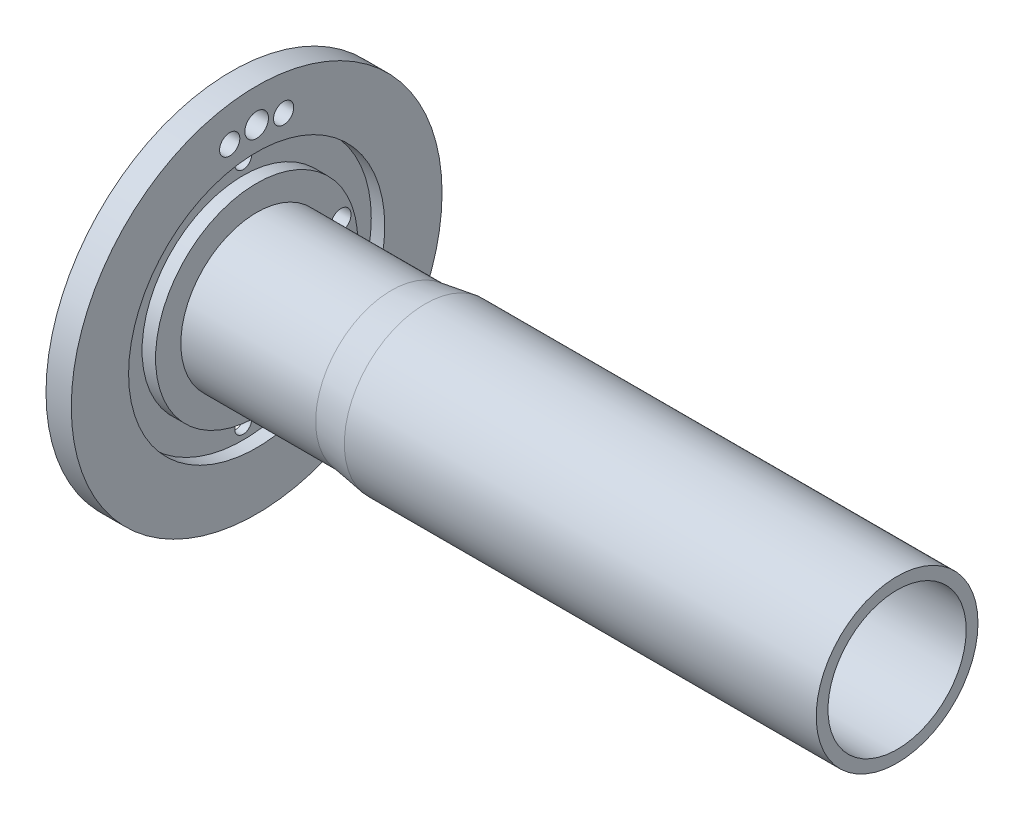
from build123d import *

# Parameters (mm, degrees)
SKETCH2_R               = 55
BOSS_EXTRUDE1_DEPTH     = 10
SKETCH3_R               = 22.5
BOSS_EXTRUDE2_DEPTH     = 40
SKETCH4_R               = 19
CUT_EXTRUDE1_DEPTH      = 93.466210045
CUT_EXTRUDE1_DEPTH_BACK = 93.466210045
SKETCH14_R              = 37.5
SKETCH14_R_2            = 30.5
CUT_EXTRUDE5_DEPTH      = 3
SKETCH15_R              = 38
SKETCH15_R_2            = 30
CUT_EXTRUDE6_DEPTH      = 4
SKETCH16_R              = 2.5
CUT_EXTRUDE7_DEPTH      = 93.466210045
SKETCH17_R              = 5
CUT_EXTRUDE8_DEPTH      = 3.7
SKETCH20_R              = 3.5
SKETCH20_R_2            = 3
CUT_EXTRUDE9_DEPTH      = 10
SKETCH21_R              = 3.5
SKETCH21_R_2            = 3
CUT_EXTRUDE10_DEPTH     = 10
SKETCH22_R              = 24
BOSS_EXTRUDE3_DEPTH     = 140
SKETCH23_R              = 20.5
CUT_EXTRUDE11_DEPTH     = 140
SKETCH25_R              = 103.972470389
CUT_EXTRUDE12_DEPTH     = 2.5


with BuildPart() as part:
    # Sketch2 → Boss-Extrude1 (new body)
    with BuildSketch(Plane(origin=(0, 0, 0), x_dir=(0, 0, -1), z_dir=(1, 0, 0))):
        Circle(SKETCH2_R)
    extrude(amount=BOSS_EXTRUDE1_DEPTH)

    # Sketch3 → Boss-Extrude2 (add)
    with BuildSketch(Plane(origin=(10, 0, 0), x_dir=(0, 0, -1), z_dir=(1, 0, 0))):
        Circle(SKETCH3_R)
    extrude(amount=BOSS_EXTRUDE2_DEPTH)

    # Sketch4 → Cut-Extrude1 (cut, two sides)
    with BuildSketch(Plane.ZY) as cut_extrude1_sk:
        Circle(SKETCH4_R)
    extrude(amount=CUT_EXTRUDE1_DEPTH, mode=Mode.SUBTRACT)
    extrude(cut_extrude1_sk.sketch, amount=-CUT_EXTRUDE1_DEPTH_BACK, mode=Mode.SUBTRACT)

    # Sketch14 → Cut-Extrude5 (cut)
    with BuildSketch(Plane.ZY):
        Circle(SKETCH14_R)
        Circle(SKETCH14_R_2, mode=Mode.SUBTRACT)
    extrude(amount=-CUT_EXTRUDE5_DEPTH, mode=Mode.SUBTRACT)

    # Sketch15 → Cut-Extrude6 (cut)
    with BuildSketch(Plane(origin=(10, 0, 0), x_dir=(0, 0, -1), z_dir=(1, 0, 0))):
        Circle(SKETCH15_R)
        Circle(SKETCH15_R_2, mode=Mode.SUBTRACT)
    extrude(amount=-CUT_EXTRUDE6_DEPTH, mode=Mode.SUBTRACT)

    # Sketch16 → Cut-Extrude7 (cut, through all)
    with BuildSketch(Plane.ZY):
        with Locations((0, 34)):
            Circle(SKETCH16_R)
        with Locations((0, -34)):
            Circle(SKETCH16_R)
    extrude(amount=-CUT_EXTRUDE7_DEPTH, mode=Mode.SUBTRACT)

    # Sketch17 → Cut-Extrude8 (cut)
    with BuildSketch(Plane.ZY):
        with Locations((0, -34)):
            Circle(SKETCH17_R)
        with Locations((0, 34)):
            Circle(SKETCH17_R)
    extrude(amount=-CUT_EXTRUDE8_DEPTH, mode=Mode.SUBTRACT)

    # Sketch20 → Cut-Extrude9 (cut)
    with BuildSketch(Plane.ZY):
        with Locations((-26, 0)):
            Circle(SKETCH20_R)
        with Locations((-25, -8)):
            Circle(SKETCH20_R_2)
        with Locations((-25, 8)):
            Circle(SKETCH20_R_2)
    extrude(amount=-CUT_EXTRUDE9_DEPTH, mode=Mode.SUBTRACT)

    # Sketch21 → Cut-Extrude10 (cut)
    with BuildSketch(Plane.ZY):
        with Locations((0, 45)):
            Circle(SKETCH21_R)
        with Locations((-8, 44)):
            Circle(SKETCH21_R_2)
        with Locations((8, 44)):
            Circle(SKETCH21_R_2)
    extrude(amount=-CUT_EXTRUDE10_DEPTH, mode=Mode.SUBTRACT)


with BuildPart() as body_2:
    # Sketch22 → Boss-Extrude3 (new body)
    with BuildSketch(Plane(origin=(60, 0, 0), x_dir=(0, 0, -1), z_dir=(1, 0, 0))):
        Circle(SKETCH22_R)
    extrude(amount=BOSS_EXTRUDE3_DEPTH)

    # Sketch23 → Cut-Extrude11 (cut)
    with BuildSketch(Plane(origin=(200, 0, 0), x_dir=(0, 0, -1), z_dir=(1, 0, 0))):
        Circle(SKETCH23_R)
    extrude(amount=-CUT_EXTRUDE11_DEPTH, mode=Mode.SUBTRACT)


    add(part.part)  # loft5 joins it to this body
    # loft up to a face of the part (loft5)
    loft([Face(Wire([body_2.edges().sort_by_distance((60, -17.495247058, 16.429130542))[0]])), Face(Wire([body_2.edges().sort_by_distance((50, -16.401794117, 15.402309883))[0]]))])

    # loft up to a face of the part (cut_loft1)
    loft([Face(Wire([body_2.edges().sort_by_distance((60, 14.943856862, 14.033215672))[0]])), Face(Wire([body_2.edges().sort_by_distance((50, 13.850403921, -13.006395013))[0]]))], mode=Mode.SUBTRACT)

    # Sketch25 → Cut-Extrude12 (cut)
    with BuildSketch(Plane.ZY):
        Circle(SKETCH25_R)
    extrude(amount=-CUT_EXTRUDE12_DEPTH, mode=Mode.SUBTRACT)


solid = body_2.part
